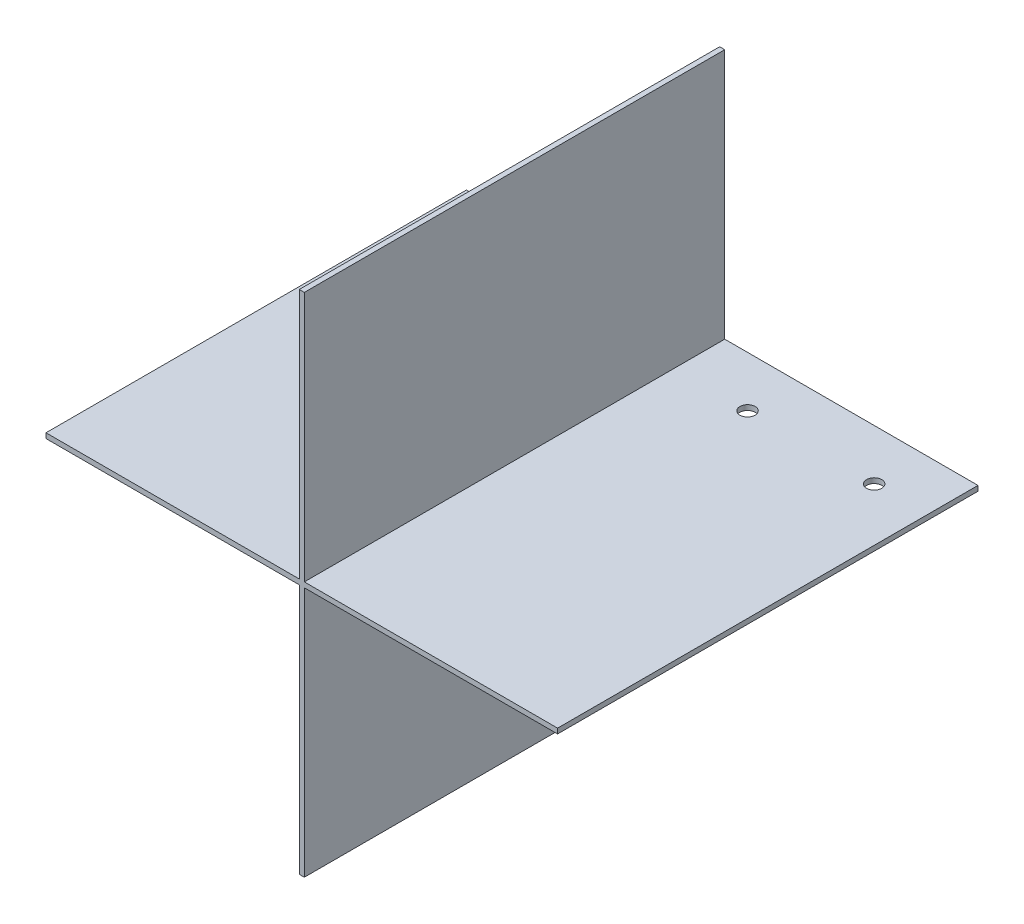
from build123d import *

# Parameters (mm, degrees)
BOSS_EXTRUDE1_DEPTH      = 0.5
BOSS_EXTRUDE1_DEPTH_BACK = 0.5
SKETCH1_W                = 83
SKETCH1_H                = 100
BOSS_EXTRUDE2_DEPTH      = 50
BOSS_EXTRUDE2_DEPTH_BACK = 51
SKETCH2_W                = 83
SKETCH2_H                = 1
CUT_EXTRUDE1_REACH       = 84.6
SKETCH3_R                = 1.5


with BuildPart() as part:
    # Sketch1 → Boss-Extrude1 (new, two sides: drawn at the far end of the back side and taken through both)
    with BuildSketch(Plane(origin=(0, 0, 0), x_dir=(0, 0, -1), z_dir=(1, 0, 0)).offset(-BOSS_EXTRUDE1_DEPTH_BACK)):
        Rectangle(SKETCH1_W, SKETCH1_H)
    extrude(amount=BOSS_EXTRUDE1_DEPTH + BOSS_EXTRUDE1_DEPTH_BACK)

    # Sketch2 → Boss-Extrude2 (add, two sides: drawn at the far end of the back side and taken through both)
    with BuildSketch(Plane(origin=(0.5, 0, 0), x_dir=(0, 0, -1), z_dir=(1, 0, 0)).offset(-BOSS_EXTRUDE2_DEPTH_BACK)):
        Rectangle(SKETCH2_W, SKETCH2_H)
    extrude(amount=BOSS_EXTRUDE2_DEPTH + BOSS_EXTRUDE2_DEPTH_BACK)

    # Sketch3 → Cut-Extrude1 (cut, up to next)
    with BuildSketch(Plane(origin=(0, 0.5, 0), x_dir=(1, 0, 0), z_dir=(0, 1, 0)), mode=Mode.PRIVATE) as cut_extrude1_sk1:
        with Locations((15, 31.5)):
            Circle(SKETCH3_R)
    cut_extrude1_tool1 = extrude(cut_extrude1_sk1.sketch, amount=-CUT_EXTRUDE1_REACH, mode=Mode.PRIVATE) & part.part
    # Sketch3 → Cut-Extrude1 (cut, up to next)
    with BuildSketch(Plane(origin=(0, 0.5, 0), x_dir=(1, 0, 0), z_dir=(0, 1, 0)), mode=Mode.PRIVATE) as cut_extrude1_sk2:
        with Locations((40, 31.5)):
            Circle(SKETCH3_R)
    cut_extrude1_tool2 = extrude(cut_extrude1_sk2.sketch, amount=-CUT_EXTRUDE1_REACH, mode=Mode.PRIVATE) & part.part
    # Sketch3 → Cut-Extrude1 (cut, up to next)
    with BuildSketch(Plane(origin=(0, 0.5, 0), x_dir=(1, 0, 0), z_dir=(0, 1, 0)), mode=Mode.PRIVATE) as cut_extrude1_sk3:
        with Locations((-40, 31.5)):
            Circle(SKETCH3_R)
    cut_extrude1_tool3 = extrude(cut_extrude1_sk3.sketch, amount=-CUT_EXTRUDE1_REACH, mode=Mode.PRIVATE) & part.part
    # Sketch3 → Cut-Extrude1 (cut, up to next)
    with BuildSketch(Plane(origin=(0, 0.5, 0), x_dir=(1, 0, 0), z_dir=(0, 1, 0)), mode=Mode.PRIVATE) as cut_extrude1_sk4:
        with Locations((-15, 31.5)):
            Circle(SKETCH3_R)
    cut_extrude1_tool4 = extrude(cut_extrude1_sk4.sketch, amount=-CUT_EXTRUDE1_REACH, mode=Mode.PRIVATE) & part.part
    add(cut_extrude1_tool1.solids().sort_by_distance((15, 0.5, -31.5))[0], mode=Mode.SUBTRACT)
    add(cut_extrude1_tool2.solids().sort_by_distance((40, 0.5, -31.5))[0], mode=Mode.SUBTRACT)
    add(cut_extrude1_tool3.solids().sort_by_distance((-40, 0.5, -31.5))[0], mode=Mode.SUBTRACT)
    add(cut_extrude1_tool4.solids().sort_by_distance((-15, 0.5, -31.5))[0], mode=Mode.SUBTRACT)


solid = part.part
